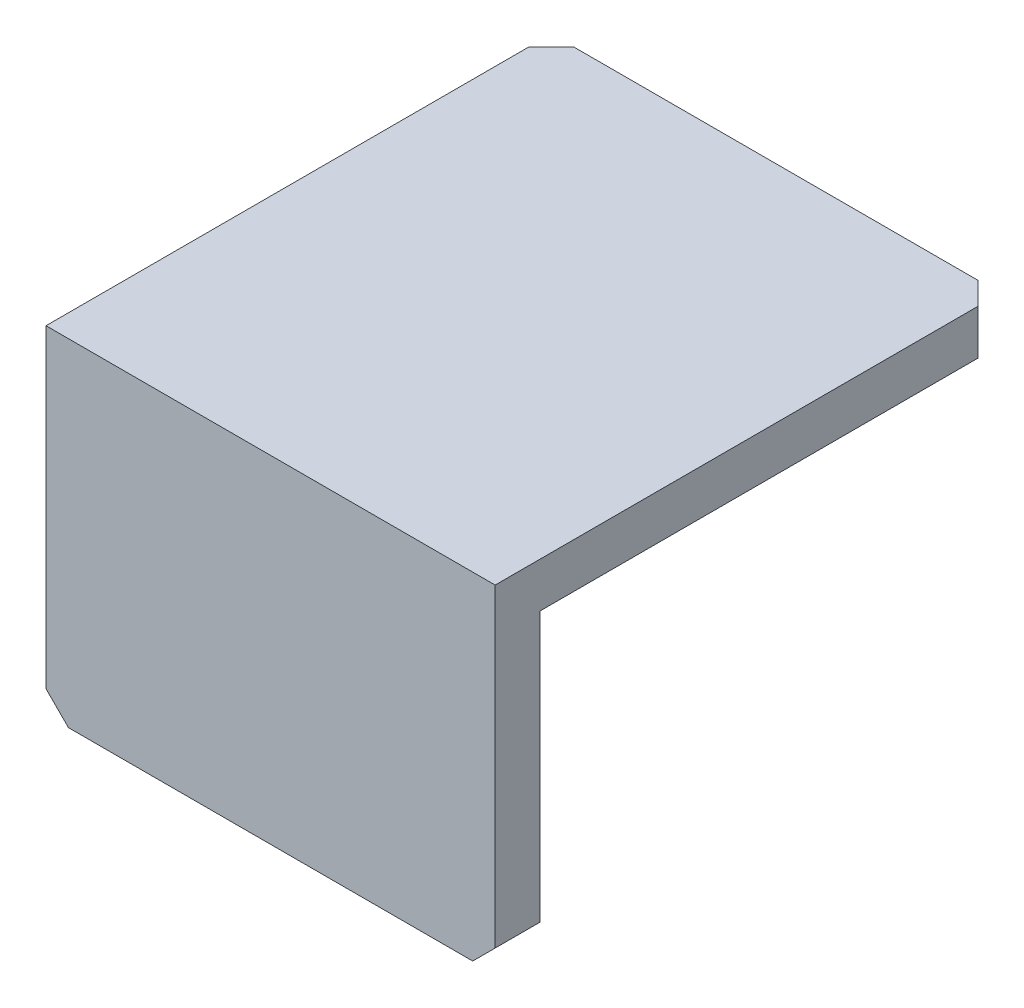
from build123d import *

# Parameters (mm, degrees)
SKETCH_1_W          = 40
SKETCH_1_H          = 30
EXTRUDE_1_DEPTH     = 45
SKETCH_6_W          = 41
SKETCH_6_H          = 26
CUT_EXTRUDE_1_DEPTH = 41
CHAMFER_1_SIZE      = 2


with BuildPart() as part:
    # 草图1 → 凸台-拉伸1 (new body)
    with BuildSketch(Plane.XY):
        Rectangle(SKETCH_1_W, SKETCH_1_H)
    extrude(amount=EXTRUDE_1_DEPTH)

    # 草图6 → 切除-拉伸1 (cut, through all)
    with BuildSketch(Plane.ZY.offset(20)):
        with Locations((20.5, -2)):
            Rectangle(SKETCH_6_W, SKETCH_6_H)
    extrude(amount=-CUT_EXTRUDE_1_DEPTH, mode=Mode.SUBTRACT)

    # 倒角1
    chamfer_1_edges = [part.edges().sort_by_distance(p)[0] for p in [
        (20, 13, 0),
        (-20, 13, 0),
        (20, -15, 43),
        (-20, -15, 43),
    ]]
    chamfer(chamfer_1_edges, length=CHAMFER_1_SIZE)


solid = part.part
